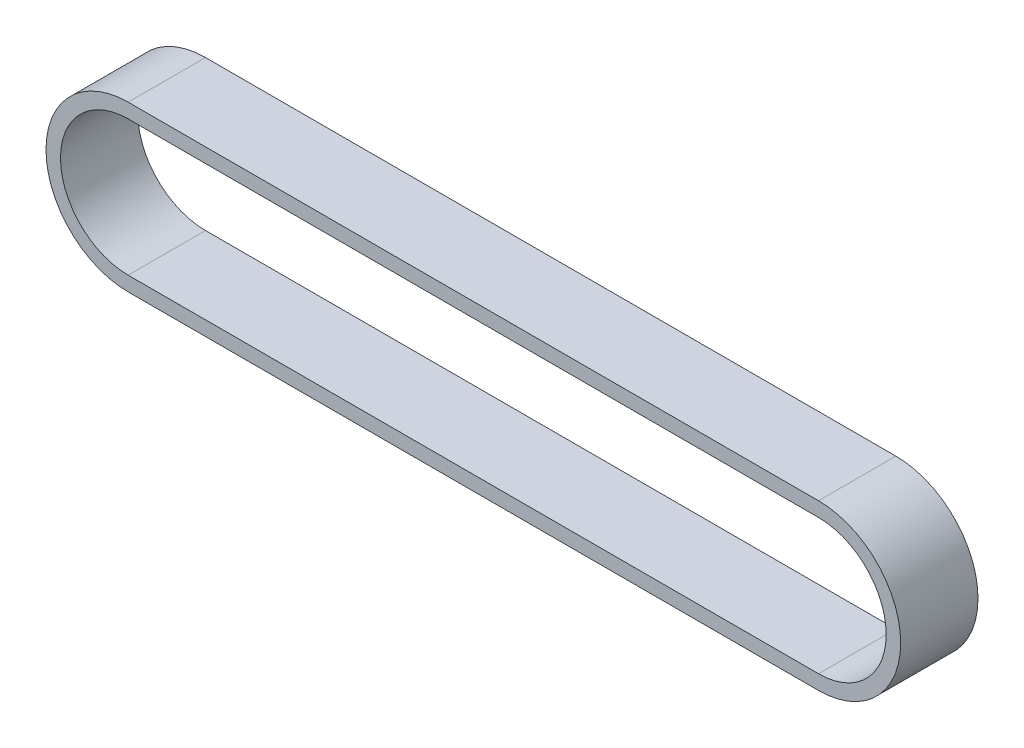
from build123d import *

# Parameters (mm, degrees)
ESTRUSIONE_ESTRUSIONE1_DEPTH = 6.4


with BuildPart() as part:
    # Schizzo1 → Estrusione-Estrusione1 (new body)
    with BuildSketch(Plane.XY):
        with BuildLine():
            Line((0, -6.8), (-57.140178509, -6.8))
            ThreePointArc((-57.140178509, -6.8), (-63.940178509, 0), (-57.140178509, 6.8))
            Line((-57.140178509, 6.8), (0, 6.8))
            ThreePointArc((0, 6.8), (6.8, 0), (0, -6.8))
        make_face()
        with BuildLine():
            Line((0, -5.6), (-57.140178509, -5.6))
            ThreePointArc((-57.140178509, -5.6), (-62.740178509, 0), (-57.140178509, 5.6))
            Line((-57.140178509, 5.6), (0, 5.6))
            ThreePointArc((0, 5.6), (5.6, 0), (0, -5.6))
        make_face(mode=Mode.SUBTRACT)
    extrude(amount=ESTRUSIONE_ESTRUSIONE1_DEPTH)


solid = part.part
